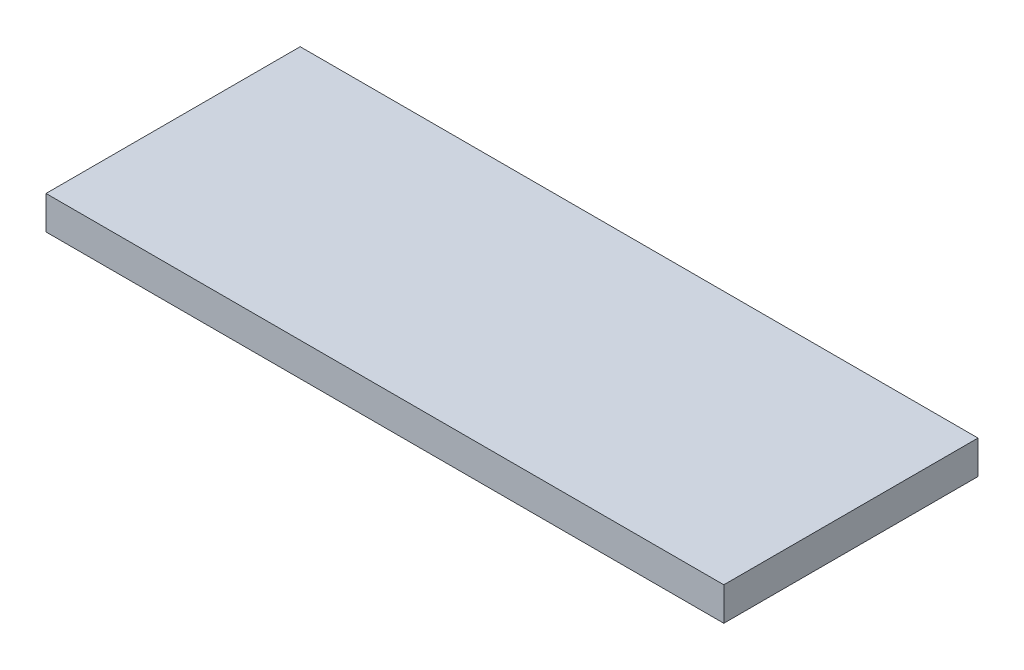
from build123d import *

# Parameters (mm, degrees)
MAIN_BASE_DIM_W = 406.4
MAIN_BASE_DIM_H = 152.4
MAIN_BASE_DEPTH = 20


with BuildPart() as part:
    # Main Base Dim → Main Base (new body)
    with BuildSketch(Plane(origin=(0, 0, 0), x_dir=(1, 0, 0), z_dir=(0, 1, 0))):
        with Locations((203.2, 76.2)):
            Rectangle(MAIN_BASE_DIM_W, MAIN_BASE_DIM_H)
    extrude(amount=MAIN_BASE_DEPTH)


solid = part.part
